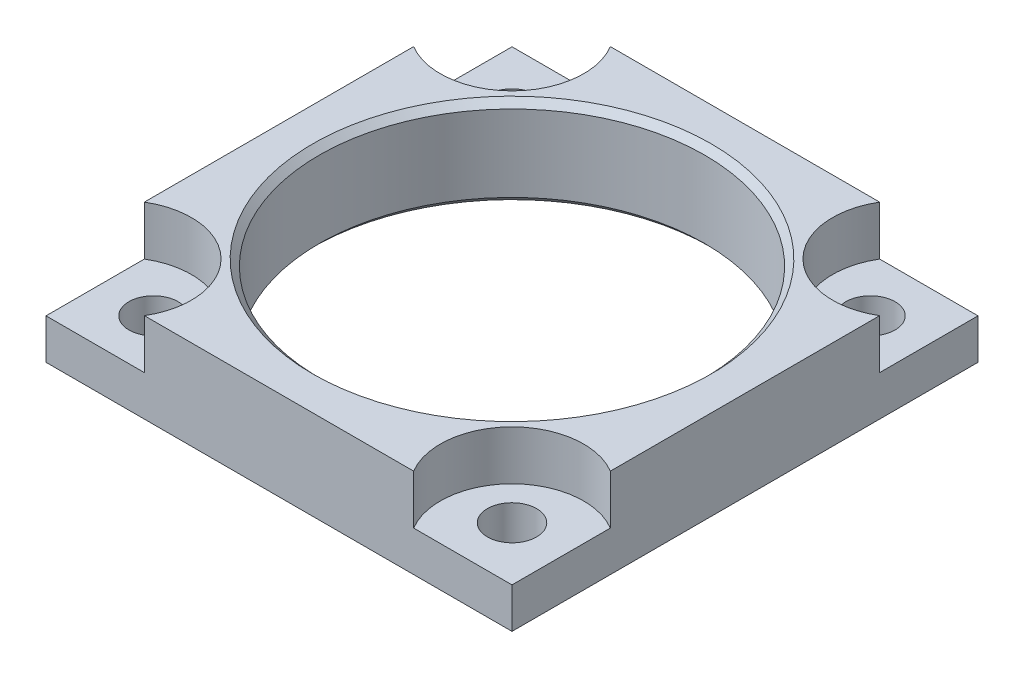
from build123d import *

# Parameters (mm, degrees)
SKETCH1_W          = 82.55
SKETCH1_H          = 82.55
SKETCH1_R          = 34.1503
EXTRUDE1_DEPTH     = 15.875
CUT_EXTRUDE1_DEPTH = 8.7376
HOLE1_D            = 8.7122
HOLE1_DEPTH        = 7.1374


with BuildPart() as part:
    # Sketch1 → Extrude1 (new body)
    with BuildSketch(Plane(origin=(0, 0, 0), x_dir=(1, 0, 0), z_dir=(0, 1, 0))):
        Rectangle(SKETCH1_W, SKETCH1_H)
        with Locations(Location((0, 0, 0), (0, 0, 270))):  # turned: the seam where the file's is
            Circle(SKETCH1_R, mode=Mode.SUBTRACT)
    extrude(amount=EXTRUDE1_DEPTH)

    # Sketch2 → Cut-Extrude1 (cut)
    with BuildSketch(Plane(origin=(0, 15.875, 0), x_dir=(1, 0, 0), z_dir=(0, 1, 0))):
        with BuildLine():
            Line((23.853264661, -41.275), (41.275, -41.275))
            Line((41.275, -41.275), (41.275, -23.853264661))
            ThreePointArc((41.275, -23.853264661), (25.766943879, -25.766943879), (23.853264661, -41.275))
        make_face()
        with BuildLine():
            Line((41.275, 41.275), (41.275, 23.853264661))
            ThreePointArc((41.275, 23.853264661), (25.766943879, 25.766943879), (23.853264661, 41.275))
            Line((23.853264661, 41.275), (41.275, 41.275))
        make_face()
        with BuildLine():
            Line((-23.853264661, 41.275), (-41.275, 41.275))
            Line((-41.275, 41.275), (-41.275, 23.853264661))
            ThreePointArc((-41.275, 23.853264661), (-25.766943879, 25.766943879), (-23.853264661, 41.275))
        make_face()
        with BuildLine():
            Line((-41.275, -41.275), (-41.275, -23.853264661))
            ThreePointArc((-41.275, -23.853264661), (-25.766943879, -25.766943879), (-23.853264661, -41.275))
            Line((-23.853264661, -41.275), (-41.275, -41.275))
        make_face()
    extrude(amount=-CUT_EXTRUDE1_DEPTH, mode=Mode.SUBTRACT)

    # Hole1
    with Locations(Plane(origin=(0, 7.1374, 0), x_dir=(-1, 0, 0), z_dir=(0, 1, 0))):
        with Locations((31.75, 31.75), (31.75, -31.75), (-31.75, 31.75), (-31.75, -31.75)):
            Hole(HOLE1_D / 2, depth=HOLE1_DEPTH)

    # Sketch5 → Cut-Revolve1 (revolve, cut)
    with BuildSketch(Plane(origin=(0, 0, 0), x_dir=(0, 0, -1), z_dir=(1, 0, 0)), mode=Mode.PRIVATE) as cut_revolve1_sk:
        Polygon((-35.306, 15.875), (-34.1503, 15.875), (-34.1503, 14.7193), align=None)
        Polygon((-34.1503, 1.1557), (-35.306, 0), (-34.1503, 0), align=None)
    revolve(cut_revolve1_sk.sketch.rotate(Axis((0, 0, 0), (0, 1, 0)), 180), axis=Axis((0, 0, 0), (0, 1, 0)), mode=Mode.SUBTRACT)  # turned: the seam where the file's is


solid = part.part
